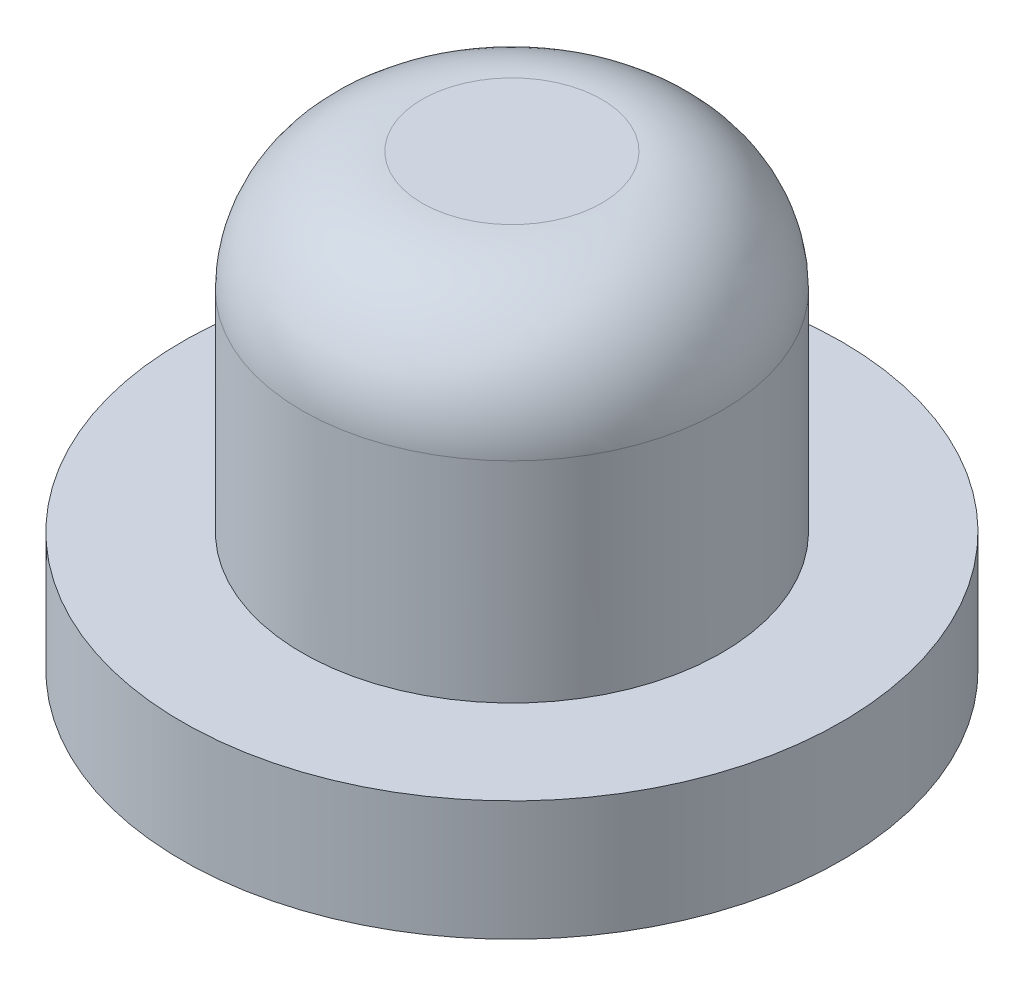
from build123d import *

# Parameters (mm, degrees)
SKIZZE1_R                       = 3.5
AUFSATZ_LINEAR_AUSTRAGEN1_DEPTH = 5.5
SKIZZE2_R                       = 5.5
AUFSATZ_LINEAR_AUSTRAGEN2_DEPTH = 2
SKIZZE3_R                       = 2
SCHNITT_LINEAR_AUSTRAGEN1_DEPTH = 0.5
VERRUNDUNG1_R                   = 2


with BuildPart() as part:
    # Skizze1 → Aufsatz-Linear austragen1 (new body)
    with BuildSketch(Plane(origin=(0, 0, 0), x_dir=(1, 0, 0), z_dir=(0, 1, 0))):
        Circle(SKIZZE1_R)
    extrude(amount=AUFSATZ_LINEAR_AUSTRAGEN1_DEPTH)

    # Skizze2 → Aufsatz-Linear austragen2 (add)
    with BuildSketch(Plane.XZ):
        Circle(SKIZZE2_R)
    extrude(amount=AUFSATZ_LINEAR_AUSTRAGEN2_DEPTH)

    # Skizze3 → Schnitt-Linear austragen1 (cut)
    with BuildSketch(Plane.XZ.offset(2)):
        Circle(SKIZZE3_R)
    extrude(amount=-SCHNITT_LINEAR_AUSTRAGEN1_DEPTH, mode=Mode.SUBTRACT)

    # Verrundung1
    verrundung1_edges = [part.edges().sort_by_distance(p)[0] for p in [
        (-3.5, 5.5, 0),
    ]]
    fillet(verrundung1_edges, radius=VERRUNDUNG1_R)


solid = part.part
